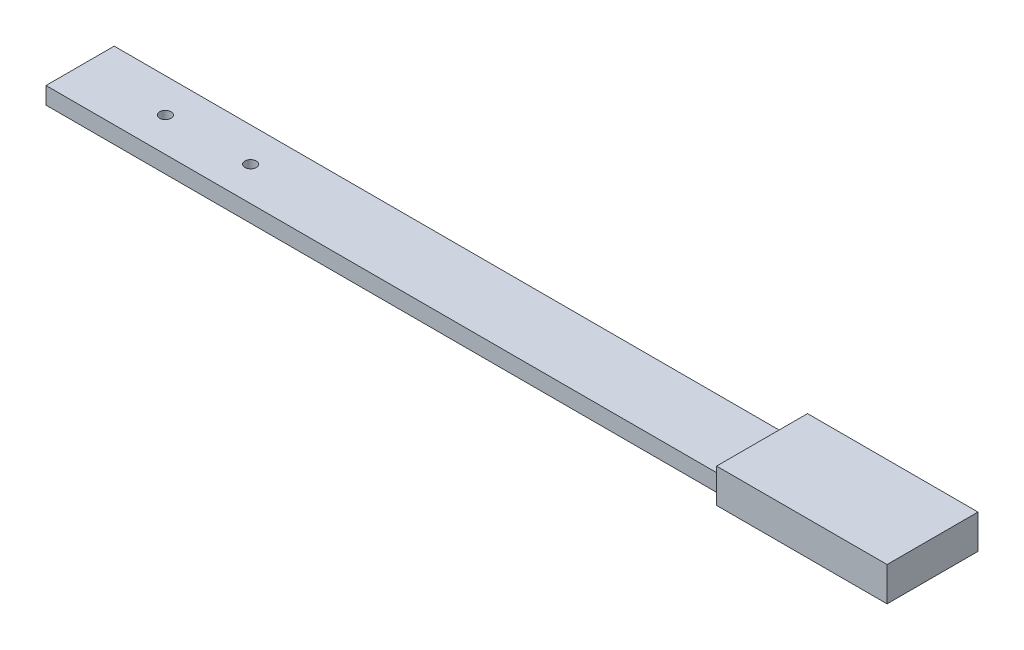
from build123d import *

# Parameters (mm, degrees)
IZIM1_W                     = 750
IZIM1_H                     = 80
IZIM1_R                     = 5
Y_KSEKLIK_EKSTR_ZYON1_DEPTH = 30
KES_EKSTR_ZYON1_DEPTH       = 600


with BuildPart() as part:
    # Çizim1 → Yükseklik-Ekstrüzyon1 (new body)
    with BuildSketch(Plane(origin=(0, 0, 0), x_dir=(1, 0, 0), z_dir=(0, 1, 0))):
        Rectangle(IZIM1_W, IZIM1_H)
        with Locations((-300, 0)):
            Circle(IZIM1_R, mode=Mode.SUBTRACT)
        with Locations((-225, 0)):
            Circle(IZIM1_R, mode=Mode.SUBTRACT)
    extrude(amount=-Y_KSEKLIK_EKSTR_ZYON1_DEPTH)

    # Çizim3 → Kes-Ekstrüzyon1 (cut)
    with BuildSketch(Plane.ZY.offset(375)):
        Polygon((-30, -30), (-30, -15), (30, -15), (30, -30), (40, -30), (40, 0), (-40, 0), (-40, -30), align=None)
    extrude(amount=-KES_EKSTR_ZYON1_DEPTH, mode=Mode.SUBTRACT)


solid = part.part
